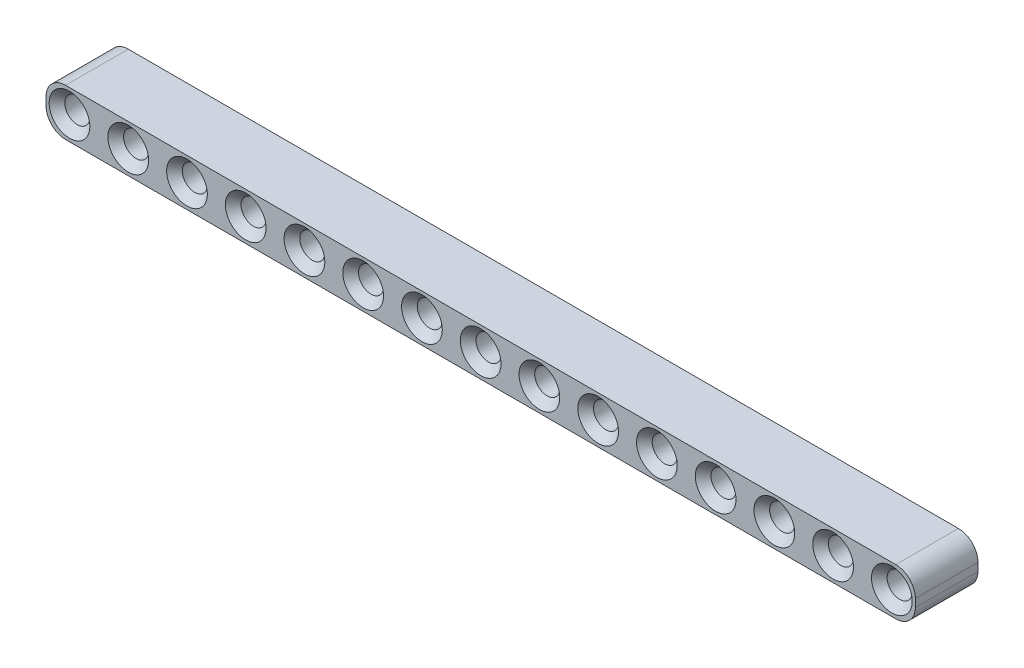
from build123d import *

# Parameters (mm, degrees)
SKETCH1_R           = 1.6
BOSS_EXTRUDE1_DEPTH = 8
CHAMFER1_SIZE       = 1


with BuildPart() as part:
    # Sketch1 → Boss-Extrude1 (new body)
    with BuildSketch(Plane.XY):
        with BuildLine():
            Line((-0.5, 3), (105.5, 3))
            ThreePointArc((105.5, 3), (107.267766953, 2.267766953), (108, 0.5))
            Line((108, 0.5), (108, -0.5))
            ThreePointArc((108, -0.5), (107.267766953, -2.267766953), (105.5, -3))
            Line((105.5, -3), (-0.5, -3))
            ThreePointArc((-0.5, -3), (-2.267766953, -2.267766953), (-3, -0.5))
            Line((-3, -0.5), (-3, 0.5))
            ThreePointArc((-3, 0.5), (-2.267766953, 2.267766953), (-0.5, 3))
        make_face()
        Circle(SKETCH1_R, mode=Mode.SUBTRACT)
        with Locations((7.5, 0)):
            Circle(SKETCH1_R, mode=Mode.SUBTRACT)
        with Locations((15, 0)):
            Circle(SKETCH1_R, mode=Mode.SUBTRACT)
        with Locations((22.5, 0)):
            Circle(SKETCH1_R, mode=Mode.SUBTRACT)
        with Locations((30, 0)):
            Circle(SKETCH1_R, mode=Mode.SUBTRACT)
        with Locations((37.5, 0)):
            Circle(SKETCH1_R, mode=Mode.SUBTRACT)
        with Locations((45, 0)):
            Circle(SKETCH1_R, mode=Mode.SUBTRACT)
        with Locations((52.5, 0)):
            Circle(SKETCH1_R, mode=Mode.SUBTRACT)
        with Locations((60, 0)):
            Circle(SKETCH1_R, mode=Mode.SUBTRACT)
        with Locations((67.5, 0)):
            Circle(SKETCH1_R, mode=Mode.SUBTRACT)
        with Locations((75, 0)):
            Circle(SKETCH1_R, mode=Mode.SUBTRACT)
        with Locations((82.5, 0)):
            Circle(SKETCH1_R, mode=Mode.SUBTRACT)
        with Locations((90, 0)):
            Circle(SKETCH1_R, mode=Mode.SUBTRACT)
        with Locations((97.5, 0)):
            Circle(SKETCH1_R, mode=Mode.SUBTRACT)
        with Locations((105, 0)):
            Circle(SKETCH1_R, mode=Mode.SUBTRACT)
    extrude(amount=BOSS_EXTRUDE1_DEPTH)

    # Chamfer1
    chamfer1_edges = [part.edges().sort_by_distance(p)[0] for p in [
        (-1.6, 0, 0),
        (-1.6, 0, 8),
        (5.9, 0, 0),
        (5.9, 0, 8),
        (13.4, 0, 0),
        (13.4, 0, 8),
        (20.9, 0, 0),
        (20.9, 0, 8),
        (28.4, 0, 0),
        (28.4, 0, 8),
        (35.9, 0, 0),
        (35.9, 0, 8),
        (43.4, 0, 0),
        (43.4, 0, 8),
        (50.9, 0, 0),
        (50.9, 0, 8),
        (58.4, 0, 0),
        (58.4, 0, 8),
        (65.9, 0, 0),
        (65.9, 0, 8),
        (73.4, 0, 0),
        (73.4, 0, 8),
        (80.9, 0, 0),
        (80.9, 0, 8),
        (88.4, 0, 0),
        (88.4, 0, 8),
        (95.9, 0, 0),
        (95.9, 0, 8),
        (103.4, 0, 0),
        (103.4, 0, 8),
    ]]
    chamfer(chamfer1_edges, length=CHAMFER1_SIZE)


solid = part.part
